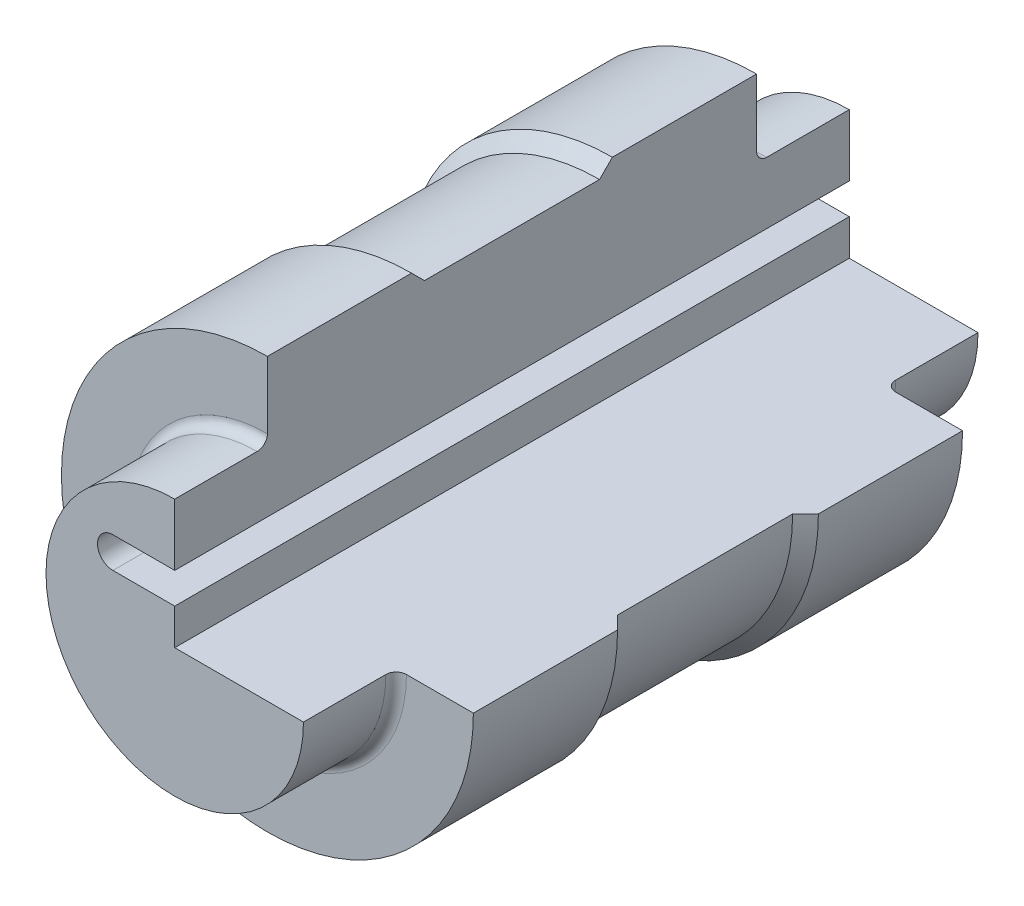
from build123d import *

# Parameters (mm, degrees)
CUT_EXTRUDE1_DEPTH      = 66.5
CUT_EXTRUDE1_DEPTH_BACK = 66.5


with BuildPart() as part:
    # Sketch1 → Revolve1 (revolve)
    with BuildSketch(Plane(origin=(0, 0, 0), x_dir=(0, 0, -1), z_dir=(1, 0, 0))):
        with BuildLine():
            Line((65.5, 0), (-65.5, 0))
            Line((-65.5, 0), (-65.5, 25))
            Line((-65.5, 25), (-49.5, 25))
            ThreePointArc((-49.5, 25), (-48.085786438, 25.585786438), (-47.5, 27))
            Line((-47.5, 27), (-47.5, 40))
            Line((-47.5, 40), (-19.5, 40))
            Line((-19.5, 40), (-17, 37.5))
            Line((-17, 37.5), (17, 37.5))
            Line((17, 37.5), (19.5, 40))
            Line((19.5, 40), (47.5, 40))
            Line((47.5, 40), (47.5, 27))
            ThreePointArc((47.5, 27), (48.085786438, 25.585786438), (49.5, 25))
            Line((49.5, 25), (65.5, 25))
            Line((65.5, 25), (65.5, 0))
        make_face()
    revolve(axis=Axis((0, 0, -65.5), (0, 0, 1)))

    # Sketch2 → Cut-Extrude1 (cut, two sides)
    with BuildSketch(Plane.XY) as cut_extrude1_sk:
        with BuildLine():
            Line((0, 40), (0, 13))
            Line((0, 13), (-12, 13))
            ThreePointArc((-12, 13), (-15, 10), (-12, 7))
            Line((-12, 7), (0, 7))
            Line((0, 7), (0, 0))
            Line((0, 0), (40, 0))
            ThreePointArc((40, 0), (28.284271247, 28.284271247), (0, 40))
        make_face()
    extrude(amount=CUT_EXTRUDE1_DEPTH, mode=Mode.SUBTRACT)
    extrude(cut_extrude1_sk.sketch, amount=-CUT_EXTRUDE1_DEPTH_BACK, mode=Mode.SUBTRACT)


solid = part.part
